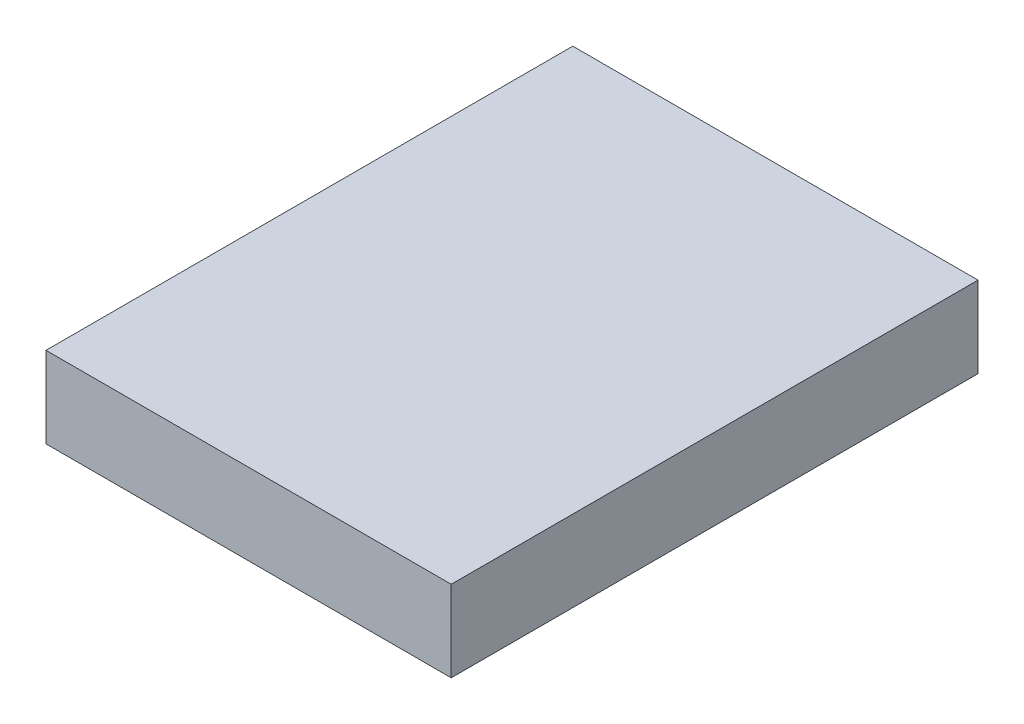
from build123d import *

# Parameters (mm, degrees)
SKETCH1_W      = 100
SKETCH1_H      = 130
EXTRUDE1_DEPTH = 20


with BuildPart() as part:
    # Sketch1 → Extrude1 (new body)
    with BuildSketch(Plane(origin=(0, 0, 0), x_dir=(1, 0, 0), z_dir=(0, 1, 0))):
        Rectangle(SKETCH1_W, SKETCH1_H)
    extrude(amount=EXTRUDE1_DEPTH)


solid = part.part
